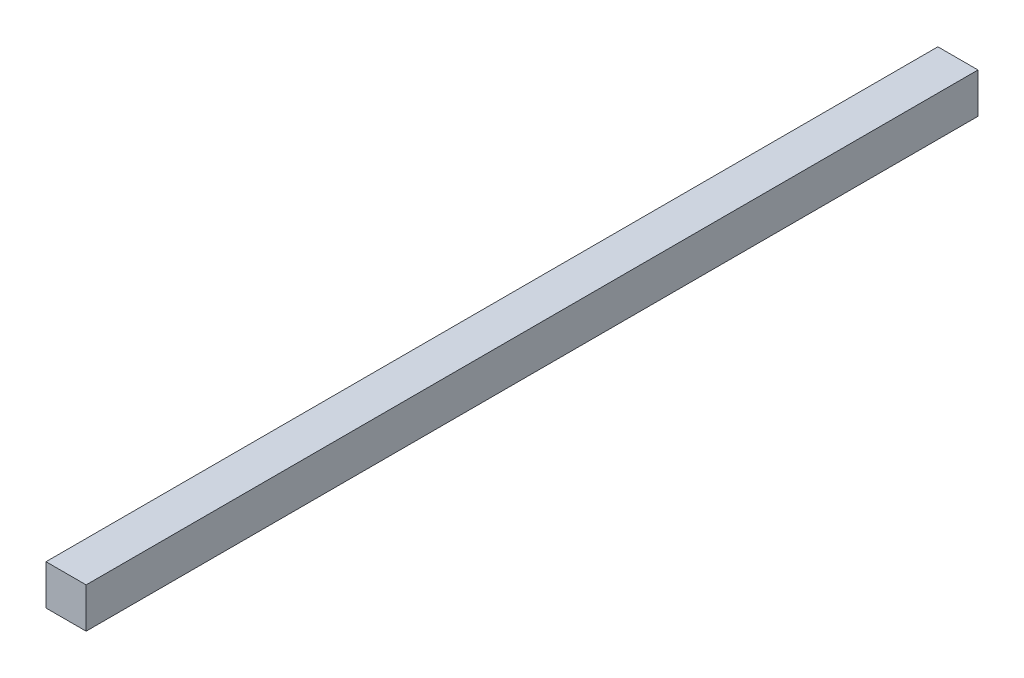
from build123d import *

# Parameters (mm, degrees)
SKETCH1_W           = 45
SKETCH1_H           = 45
BOSS_EXTRUDE1_DEPTH = 1000


with BuildPart() as part:
    # Sketch1 → Boss-Extrude1 (new body)
    with BuildSketch(Plane.XY):
        with Locations((22.5, 22.5)):
            Rectangle(SKETCH1_W, SKETCH1_H)
    extrude(amount=BOSS_EXTRUDE1_DEPTH)


solid = part.part
